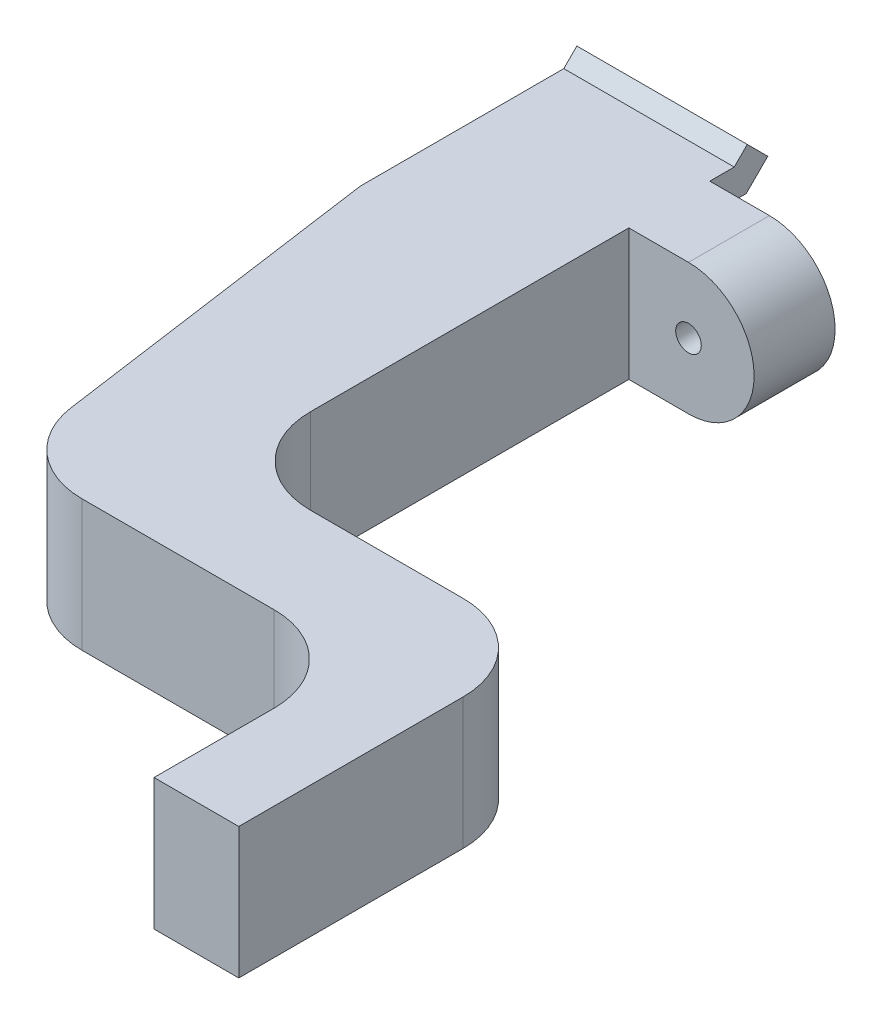
from build123d import *

# Parameters (mm, degrees)
SKETCH2_W           = 10
SKETCH2_H           = 14.768412439
BOSS_EXTRUDE1_DEPTH = 5
BOSS_EXTRUDE4_DEPTH = 10
SKETCH9_W           = 10
SKETCH9_H           = 3.18
SKETCH9_H_2         = 3.888412439
CUT_EXTRUDE3_DEPTH  = 5
BOSS_EXTRUDE5_DEPTH = 7.7
SKETCH12_R          = 0.75
BOSS_EXTRUDE7_DEPTH = 4.75


with BuildPart() as part:
    # Sketch2 → Boss-Extrude1 (new body)
    with BuildSketch(Plane.XY):
        with Locations((0, 1.566049366)):
            Rectangle(SKETCH2_W, SKETCH2_H)
    extrude(amount=BOSS_EXTRUDE1_DEPTH)

    # Sketch8 → Boss-Extrude4 (add)
    with BuildSketch(Plane.ZY.offset(5)):
        Polygon((-0.15, 5.770255585), (0, 5.770255585), (0, 4.070255585), (-0.15, 4.070255585), (-2.137867966, 4.070255585), (-3.402081528, 5.334469147), (-2.2, 6.536550675), (-1.43370491, 5.770255585), align=None)
        Polygon((-0.15, -1.929744415), (0, -1.929744415), (0, -0.229744415), (-0.15, -0.229744415), (-1.43370491, -0.229744415), (-2.2, 0.536550675), (-3.402081528, -0.665530853), (-2.137867966, -1.929744415), align=None)
    extrude(amount=-BOSS_EXTRUDE4_DEPTH)

    # Sketch9 → Cut-Extrude3 (cut)
    with BuildSketch(Plane(origin=(0, 0, 0), x_dir=(-1, 0, 0), z_dir=(0, 0, -1))):
        with Locations((0, 7.360255585)):
            Rectangle(SKETCH9_W, SKETCH9_H)
        with Locations((0, -3.873950635)):
            Rectangle(SKETCH9_W, SKETCH9_H_2)
    extrude(amount=-CUT_EXTRUDE3_DEPTH, mode=Mode.SUBTRACT)

    # Sketch10 → Boss-Extrude5 (add)
    with BuildSketch(Plane(origin=(0, 5.770255585, 0), x_dir=(1, 0, 0), z_dir=(0, 1, 0))):
        with BuildLine():
            Line((-5, -5), (-5, -10.5))
            Line((-5, -10.5), (-2.224545314, -30.248386236))
            ThreePointArc((-2.224545314, -30.248386236), (-0.553500116, -33.326068633), (2.726795029, -34.552520732))
            Line((2.726795029, -34.552520732), (13.995577548, -34.552520732))
            ThreePointArc((13.995577548, -34.552520732), (17.531111453, -36.016986826), (18.995577548, -39.552520732))
            Line((18.995577548, -39.552520732), (18.995577548, -46.600725687))
            Line((18.995577548, -46.600725687), (23.967852608, -46.600725687))
            Line((23.967852608, -46.600725687), (23.967852608, -33.43279758))
            ThreePointArc((23.967852608, -33.43279758), (22.503386514, -29.897263674), (18.967852608, -28.43279758))
            Line((18.967852608, -28.43279758), (10, -28.43279758))
            ThreePointArc((10, -28.43279758), (6.464466094, -26.968331486), (5, -23.43279758))
            Line((5, -23.43279758), (5, -14))
            Line((5, -14), (5, -5))
            Line((5, -5), (-5, -5))
        make_face()
    extrude(amount=-BOSS_EXTRUDE5_DEPTH)

    # Sketch12 → Boss-Extrude7 (add)
    with BuildSketch(Plane.XY):
        with BuildLine():
            Line((5, 5.770255585), (8.5, 5.770255585))
            ThreePointArc((8.5, 5.770255585), (12.35, 1.920255585), (8.5, -1.929744415))
            Line((8.5, -1.929744415), (5, -1.929744415))
            Line((5, -1.929744415), (5, 5.770255585))
        make_face()
        with Locations((8.5, 1.920255585)):
            Circle(SKETCH12_R, mode=Mode.SUBTRACT)
    extrude(amount=BOSS_EXTRUDE7_DEPTH)


solid = part.part
